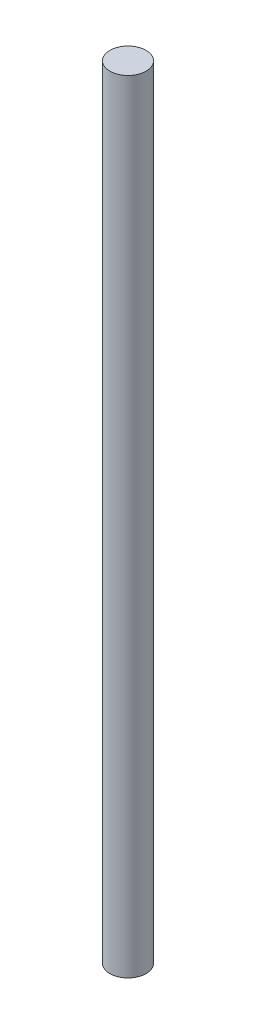
from build123d import *

# Parameters (mm, degrees)
SKETCH2_R           = 1.825
BOSS_EXTRUDE1_DEPTH = 79


with BuildPart() as part:
    # Sketch2 → Boss-Extrude1 (new body)
    with BuildSketch(Plane(origin=(0, 0, 0), x_dir=(1, 0, 0), z_dir=(0, 1, 0))):
        Circle(SKETCH2_R)
    extrude(amount=BOSS_EXTRUDE1_DEPTH)


solid = part.part
